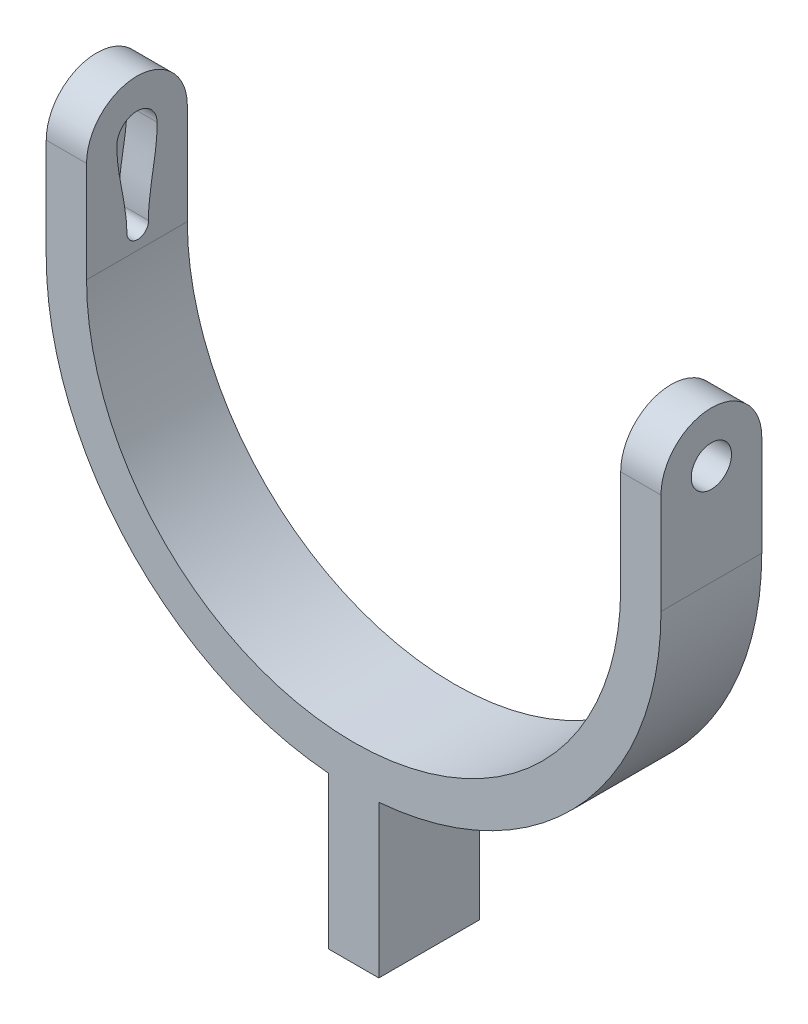
from build123d import *

# Parameters (mm, degrees)
BOSS_EXTRUDE1_DEPTH     = 10
SKETCH3_R               = 5
SKETCH3_R_2             = 2
BOSS_EXTRUDE2_DEPTH     = 4
BOSS_EXTRUDE3_START     = -57
SKETCH3_2_R             = 5
SKETCH3_2_R_2           = 2
BOSS_EXTRUDE3_DEPTH     = 4
CUT_EXTRUDE1_DEPTH      = 1
CUT_EXTRUDE1_DEPTH_BACK = 62
CUT_EXTRUDE2_START      = -4
SKETCH4_R               = 1.074869596
CUT_EXTRUDE2_DEPTH      = 3


with BuildPart() as part:
    # Sketch2 → Boss-Extrude1 (new body)
    with BuildSketch(Plane.XY):
        with BuildLine():
            Line((-30.5, 0), (-30.5, 10))
            Line((-30.5, 10), (-26.5, 10))
            Line((-26.5, 10), (-26.5, 0))
            ThreePointArc((-26.5, 0), (0, -26.5), (26.5, 0))
            Line((26.5, 0), (26.5, 10))
            Line((26.5, 10), (30.5, 10))
            Line((30.5, 10), (30.5, 0))
            ThreePointArc((30.5, 0), (0, -30.5), (-30.5, 0))
        make_face()
        with BuildLine():
            ThreePointArc((2.5, -30.397368307), (0, -30.5), (-2.5, -30.397368307))
            Line((-2.5, -30.397368307), (-2.5, -45.5))
            Line((-2.5, -45.5), (2.5, -45.5))
            Line((2.5, -45.5), (2.5, -30.397368307))
        make_face()
    extrude(amount=BOSS_EXTRUDE1_DEPTH)

    # Sketch3 → Boss-Extrude2 (add)
    with BuildSketch(Plane(origin=(30.5, 0, 0), x_dir=(0, 0, -1), z_dir=(1, 0, 0))):
        with Locations((-5, 10)):
            Circle(SKETCH3_R)
        with Locations((-5, 10)):
            Circle(SKETCH3_R_2, mode=Mode.SUBTRACT)
    extrude(amount=-BOSS_EXTRUDE2_DEPTH)

    # Sketch3_2 → Boss-Extrude3 (add)
    with BuildSketch(Plane(origin=(30.5, 0, 0), x_dir=(0, 0, -1), z_dir=(1, 0, 0)).offset(BOSS_EXTRUDE3_START)):
        with Locations((-5, 10)):
            Circle(SKETCH3_2_R)
        with Locations((-5, 10)):
            Circle(SKETCH3_2_R_2, mode=Mode.SUBTRACT)
    extrude(amount=-BOSS_EXTRUDE3_DEPTH)

    # Sketch3_3 → Cut-Extrude1 (cut, two sides)
    with BuildSketch(Plane(origin=(30.5, 0, 0), x_dir=(0, 0, -1), z_dir=(1, 0, 0))) as cut_extrude1_sk:
        with BuildLine():
            Line((-7, 10), (-3, 10))
            ThreePointArc((-3, 10), (-5, 12), (-7, 10))
        make_face()
        with BuildLine():
            ThreePointArc((-7, 10), (-5, 8), (-3, 10))
            Line((-3, 10), (-7, 10))
        make_face()
    extrude(amount=CUT_EXTRUDE1_DEPTH, mode=Mode.SUBTRACT)
    extrude(cut_extrude1_sk.sketch, amount=-CUT_EXTRUDE1_DEPTH_BACK, mode=Mode.SUBTRACT)

    # Sketch4 → Cut-Extrude2 (cut)
    with BuildSketch(Plane.ZY.offset(30.5).offset(CUT_EXTRUDE2_START)):
        with BuildLine():
            ThreePointArc((7, 10), (6.935947021, 9.497895298), (6.747890868, 9.027951898))
            ThreePointArc((6.747890868, 9.027951898), (4.964769811, 8.000310316), (3.218953718, 9.090124106))
            ThreePointArc((3.218953718, 9.090124106), (3.051214906, 9.550292696), (3.00035031, 10.03743152))
            add(Edge.make_bspline(
                [(3.00035031, 10.03743152), (2.976363567, 8.756022572), (3.388420112, 6.104237748), (3.877065914, 3.442029618), (3.850449076, 2.020117001)],
                knots=[0, 0, 0, 0, 0.472301591, 1, 1, 1, 1], degree=3))
            ThreePointArc((3.850449076, 2.020117001), (4.935189345, 3.074822528), (6, 2))
            add(Edge.make_bspline(
                [(7, 10), (7, 8.718366567), (6.538385461, 6.074758168), (6, 3.422161716), (6, 2)],
                knots=[0, 0, 0, 0, 0.472301591, 1, 1, 1, 1], degree=3))
        make_face()
        with Locations((4.925130404, 2)):
            Circle(SKETCH4_R)
    extrude(amount=CUT_EXTRUDE2_DEPTH, mode=Mode.SUBTRACT)


solid = part.part
